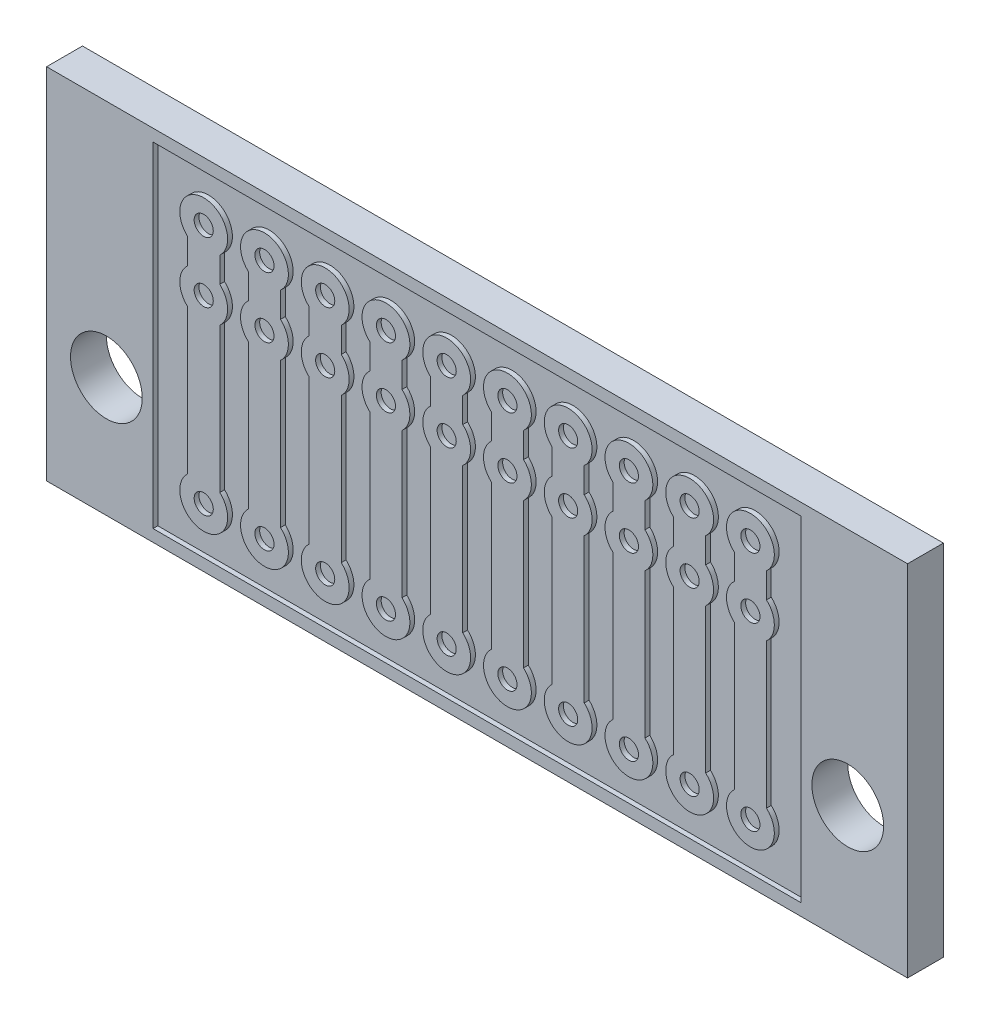
from build123d import *

# Parameters (mm, degrees)
SKETCH1_W           = 36
SKETCH1_H           = 15
BOSS_EXTRUDE3_DEPTH = 1.5
SKETCH3_W           = 27.097499574
SKETCH3_H           = 14
CUT_EXTRUDE1_DEPTH  = 0.2
SKETCH5_R           = 1.5
CUT_EXTRUDE3_DEPTH  = 10.2
SKETCH6_R           = 0.4
CUT_EXTRUDE4_DEPTH  = 0.2


with BuildPart() as part:
    # Sketch1 → Boss-Extrude3 (new body)
    with BuildSketch(Plane.XY):
        Rectangle(SKETCH1_W, SKETCH1_H)
    extrude(amount=BOSS_EXTRUDE3_DEPTH)

    # Sketch3 → Cut-Extrude1 (cut)
    with BuildSketch(Plane.XY.offset(1.5)):
        Rectangle(SKETCH3_W, SKETCH3_H)
        with BuildLine():
            Line((3.138865239, -4.298664629), (3.138865239, 1.758664629))
            ThreePointArc((3.138865239, 1.758664629), (2.81, 2.5), (3.138865239, 3.241335371))
            Line((3.138865239, 3.241335371), (3.138865239, 4.298664629))
            ThreePointArc((3.138865239, 4.298664629), (2.876904246, 5.399628022), (3.81, 6.04))
            ThreePointArc((3.81, 6.04), (4.743095754, 5.399628022), (4.481134761, 4.298664629))
            Line((4.481134761, 4.298664629), (4.481134761, 3.241335371))
            ThreePointArc((4.481134761, 3.241335371), (4.81, 2.5), (4.481134761, 1.758664629))
            Line((4.481134761, 1.758664629), (4.481134761, -4.298664629))
            ThreePointArc((4.481134761, -4.298664629), (4.743095754, -5.399628022), (3.81, -6.04))
            ThreePointArc((3.81, -6.04), (2.876904246, -5.399628022), (3.138865239, -4.298664629))
        make_face(mode=Mode.SUBTRACT)
        with BuildLine():
            Line((0.598865239, 3.241335371), (0.598865239, 4.298664629))
            ThreePointArc((0.598865239, 4.298664629), (0.336904246, 5.399628022), (1.27, 6.04))
            ThreePointArc((1.27, 6.04), (2.203095754, 5.399628022), (1.941134761, 4.298664629))
            Line((1.941134761, 4.298664629), (1.941134761, 3.241335371))
            ThreePointArc((1.941134761, 3.241335371), (2.27, 2.5), (1.941134761, 1.758664629))
            Line((1.941134761, 1.758664629), (1.941134761, -4.298664629))
            ThreePointArc((1.941134761, -4.298664629), (2.203095754, -5.399628022), (1.27, -6.04))
            ThreePointArc((1.27, -6.04), (0.336904246, -5.399628022), (0.598865239, -4.298664629))
            Line((0.598865239, -4.298664629), (0.598865239, 1.758664629))
            ThreePointArc((0.598865239, 1.758664629), (0.27, 2.5), (0.598865239, 3.241335371))
        make_face(mode=Mode.SUBTRACT)
        with BuildLine():
            Line((5.678865239, -4.298664629), (5.678865239, 1.758664629))
            ThreePointArc((5.678865239, 1.758664629), (5.35, 2.5), (5.678865239, 3.241335371))
            Line((5.678865239, 3.241335371), (5.678865239, 4.298664629))
            ThreePointArc((5.678865239, 4.298664629), (5.416904246, 5.399628022), (6.35, 6.04))
            ThreePointArc((6.35, 6.04), (7.283095754, 5.399628022), (7.021134761, 4.298664629))
            Line((7.021134761, 4.298664629), (7.021134761, 3.241335371))
            ThreePointArc((7.021134761, 3.241335371), (7.35, 2.5), (7.021134761, 1.758664629))
            Line((7.021134761, 1.758664629), (7.021134761, -4.298664629))
            ThreePointArc((7.021134761, -4.298664629), (7.283095754, -5.399628022), (6.35, -6.04))
            ThreePointArc((6.35, -6.04), (5.416904246, -5.399628022), (5.678865239, -4.298664629))
        make_face(mode=Mode.SUBTRACT)
        with BuildLine():
            Line((8.218865239, -4.298664629), (8.218865239, 1.758664629))
            ThreePointArc((8.218865239, 1.758664629), (7.89, 2.5), (8.218865239, 3.241335371))
            Line((8.218865239, 3.241335371), (8.218865239, 4.298664629))
            ThreePointArc((8.218865239, 4.298664629), (7.956904246, 5.399628022), (8.89, 6.04))
            ThreePointArc((8.89, 6.04), (9.823095754, 5.399628022), (9.561134761, 4.298664629))
            Line((9.561134761, 4.298664629), (9.561134761, 3.241335371))
            ThreePointArc((9.561134761, 3.241335371), (9.89, 2.5), (9.561134761, 1.758664629))
            Line((9.561134761, 1.758664629), (9.561134761, -4.298664629))
            ThreePointArc((9.561134761, -4.298664629), (9.823095754, -5.399628022), (8.89, -6.04))
            ThreePointArc((8.89, -6.04), (7.956904246, -5.399628022), (8.218865239, -4.298664629))
        make_face(mode=Mode.SUBTRACT)
        with BuildLine():
            Line((10.758865239, -4.298664629), (10.758865239, 1.758664629))
            ThreePointArc((10.758865239, 1.758664629), (10.43, 2.5), (10.758865239, 3.241335371))
            Line((10.758865239, 3.241335371), (10.758865239, 4.298664629))
            ThreePointArc((10.758865239, 4.298664629), (10.496904246, 5.399628022), (11.43, 6.04))
            ThreePointArc((11.43, 6.04), (12.363095754, 5.399628022), (12.101134761, 4.298664629))
            Line((12.101134761, 4.298664629), (12.101134761, 3.241335371))
            ThreePointArc((12.101134761, 3.241335371), (12.43, 2.5), (12.101134761, 1.758664629))
            Line((12.101134761, 1.758664629), (12.101134761, -4.298664629))
            ThreePointArc((12.101134761, -4.298664629), (12.363095754, -5.399628022), (11.43, -6.04))
            ThreePointArc((11.43, -6.04), (10.496904246, -5.399628022), (10.758865239, -4.298664629))
        make_face(mode=Mode.SUBTRACT)
        with BuildLine():
            Line((-0.598865239, -4.298664629), (-0.598865239, 1.758664629))
            ThreePointArc((-0.598865239, 1.758664629), (-0.27, 2.5), (-0.598865239, 3.241335371))
            Line((-0.598865239, 3.241335371), (-0.598865239, 4.298664629))
            ThreePointArc((-0.598865239, 4.298664629), (-0.336904246, 5.399628022), (-1.27, 6.04))
            ThreePointArc((-1.27, 6.04), (-2.203095754, 5.399628022), (-1.941134761, 4.298664629))
            Line((-1.941134761, 4.298664629), (-1.941134761, 3.241335371))
            ThreePointArc((-1.941134761, 3.241335371), (-2.27, 2.5), (-1.941134761, 1.758664629))
            Line((-1.941134761, 1.758664629), (-1.941134761, -4.298664629))
            ThreePointArc((-1.941134761, -4.298664629), (-2.203095754, -5.399628022), (-1.27, -6.04))
            ThreePointArc((-1.27, -6.04), (-0.336904246, -5.399628022), (-0.598865239, -4.298664629))
        make_face(mode=Mode.SUBTRACT)
        with BuildLine():
            Line((-3.138865239, -4.298664629), (-3.138865239, 1.758664629))
            ThreePointArc((-3.138865239, 1.758664629), (-2.81, 2.5), (-3.138865239, 3.241335371))
            Line((-3.138865239, 3.241335371), (-3.138865239, 4.298664629))
            ThreePointArc((-3.138865239, 4.298664629), (-2.876904246, 5.399628022), (-3.81, 6.04))
            ThreePointArc((-3.81, 6.04), (-4.743095754, 5.399628022), (-4.481134761, 4.298664629))
            Line((-4.481134761, 4.298664629), (-4.481134761, 3.241335371))
            ThreePointArc((-4.481134761, 3.241335371), (-4.81, 2.5), (-4.481134761, 1.758664629))
            Line((-4.481134761, 1.758664629), (-4.481134761, -4.298664629))
            ThreePointArc((-4.481134761, -4.298664629), (-4.743095754, -5.399628022), (-3.81, -6.04))
            ThreePointArc((-3.81, -6.04), (-2.876904246, -5.399628022), (-3.138865239, -4.298664629))
        make_face(mode=Mode.SUBTRACT)
        with BuildLine():
            Line((-5.678865239, -4.298664629), (-5.678865239, 1.758664629))
            ThreePointArc((-5.678865239, 1.758664629), (-5.35, 2.5), (-5.678865239, 3.241335371))
            Line((-5.678865239, 3.241335371), (-5.678865239, 4.298664629))
            ThreePointArc((-5.678865239, 4.298664629), (-5.416904246, 5.399628022), (-6.35, 6.04))
            ThreePointArc((-6.35, 6.04), (-7.283095754, 5.399628022), (-7.021134761, 4.298664629))
            Line((-7.021134761, 4.298664629), (-7.021134761, 3.241335371))
            ThreePointArc((-7.021134761, 3.241335371), (-7.35, 2.5), (-7.021134761, 1.758664629))
            Line((-7.021134761, 1.758664629), (-7.021134761, -4.298664629))
            ThreePointArc((-7.021134761, -4.298664629), (-7.283095754, -5.399628022), (-6.35, -6.04))
            ThreePointArc((-6.35, -6.04), (-5.416904246, -5.399628022), (-5.678865239, -4.298664629))
        make_face(mode=Mode.SUBTRACT)
        with BuildLine():
            Line((-8.218865239, -4.298664629), (-8.218865239, 1.758664629))
            ThreePointArc((-8.218865239, 1.758664629), (-7.89, 2.5), (-8.218865239, 3.241335371))
            Line((-8.218865239, 3.241335371), (-8.218865239, 4.298664629))
            ThreePointArc((-8.218865239, 4.298664629), (-7.956904246, 5.399628022), (-8.89, 6.04))
            ThreePointArc((-8.89, 6.04), (-9.823095754, 5.399628022), (-9.561134761, 4.298664629))
            Line((-9.561134761, 4.298664629), (-9.561134761, 3.241335371))
            ThreePointArc((-9.561134761, 3.241335371), (-9.89, 2.5), (-9.561134761, 1.758664629))
            Line((-9.561134761, 1.758664629), (-9.561134761, -4.298664629))
            ThreePointArc((-9.561134761, -4.298664629), (-9.823095754, -5.399628022), (-8.89, -6.04))
            ThreePointArc((-8.89, -6.04), (-7.956904246, -5.399628022), (-8.218865239, -4.298664629))
        make_face(mode=Mode.SUBTRACT)
        with BuildLine():
            Line((-10.758865239, -4.298664629), (-10.758865239, 1.758664629))
            ThreePointArc((-10.758865239, 1.758664629), (-10.43, 2.5), (-10.758865239, 3.241335371))
            Line((-10.758865239, 3.241335371), (-10.758865239, 4.298664629))
            ThreePointArc((-10.758865239, 4.298664629), (-10.496904246, 5.399628022), (-11.43, 6.04))
            ThreePointArc((-11.43, 6.04), (-12.363095754, 5.399628022), (-12.101134761, 4.298664629))
            Line((-12.101134761, 4.298664629), (-12.101134761, 3.241335371))
            ThreePointArc((-12.101134761, 3.241335371), (-12.43, 2.5), (-12.101134761, 1.758664629))
            Line((-12.101134761, 1.758664629), (-12.101134761, -4.298664629))
            ThreePointArc((-12.101134761, -4.298664629), (-12.363095754, -5.399628022), (-11.43, -6.04))
            ThreePointArc((-11.43, -6.04), (-10.496904246, -5.399628022), (-10.758865239, -4.298664629))
        make_face(mode=Mode.SUBTRACT)
    extrude(amount=-CUT_EXTRUDE1_DEPTH, mode=Mode.SUBTRACT)

    # Sketch5 → Cut-Extrude3 (cut)
    with BuildSketch(Plane.XY.offset(1.5)):
        with Locations((-15.5, -2.5)):
            Circle(SKETCH5_R)
        with Locations((15.5, -2.5)):
            Circle(SKETCH5_R)
    extrude(amount=-CUT_EXTRUDE3_DEPTH, mode=Mode.SUBTRACT)

    # Sketch6 → Cut-Extrude4 (cut)
    with BuildSketch(Plane.XY.offset(1.5)):
        with Locations((-11.43, -5.04)):
            Circle(SKETCH6_R)
        with Locations((-11.43, 2.5)):
            Circle(SKETCH6_R)
        with Locations((-11.43, 5.04)):
            Circle(SKETCH6_R)
        with Locations((-8.89, 5.04)):
            Circle(SKETCH6_R)
        with Locations((-8.89, 2.5)):
            Circle(SKETCH6_R)
        with Locations((-8.89, -5.04)):
            Circle(SKETCH6_R)
        with Locations((-6.35, 5.04)):
            Circle(SKETCH6_R)
        with Locations((-6.35, 2.5)):
            Circle(SKETCH6_R)
        with Locations((-6.35, -5.04)):
            Circle(SKETCH6_R)
        with Locations((-3.81, 5.04)):
            Circle(SKETCH6_R)
        with Locations((-3.81, 2.5)):
            Circle(SKETCH6_R)
        with Locations((-3.81, -5.04)):
            Circle(SKETCH6_R)
        with Locations((-1.27, 5.04)):
            Circle(SKETCH6_R)
        with Locations((-1.27, 2.5)):
            Circle(SKETCH6_R)
        with Locations((-1.27, -5.04)):
            Circle(SKETCH6_R)
        with Locations((1.27, 5.04)):
            Circle(SKETCH6_R)
        with Locations((1.27, 2.5)):
            Circle(SKETCH6_R)
        with Locations((1.27, -5.04)):
            Circle(SKETCH6_R)
        with Locations((3.81, 5.04)):
            Circle(SKETCH6_R)
        with Locations((3.81, 2.5)):
            Circle(SKETCH6_R)
        with Locations((3.81, -5.04)):
            Circle(SKETCH6_R)
        with Locations((6.35, 5.04)):
            Circle(SKETCH6_R)
        with Locations((6.35, 2.5)):
            Circle(SKETCH6_R)
        with Locations((6.35, -5.04)):
            Circle(SKETCH6_R)
        with Locations((8.89, 5.04)):
            Circle(SKETCH6_R)
        with Locations((8.89, 2.5)):
            Circle(SKETCH6_R)
        with Locations((8.89, -5.04)):
            Circle(SKETCH6_R)
        with Locations((11.43, 5.04)):
            Circle(SKETCH6_R)
        with Locations((11.43, 2.5)):
            Circle(SKETCH6_R)
        with Locations((11.43, -5.04)):
            Circle(SKETCH6_R)
    extrude(amount=-CUT_EXTRUDE4_DEPTH, mode=Mode.SUBTRACT)


solid = part.part
